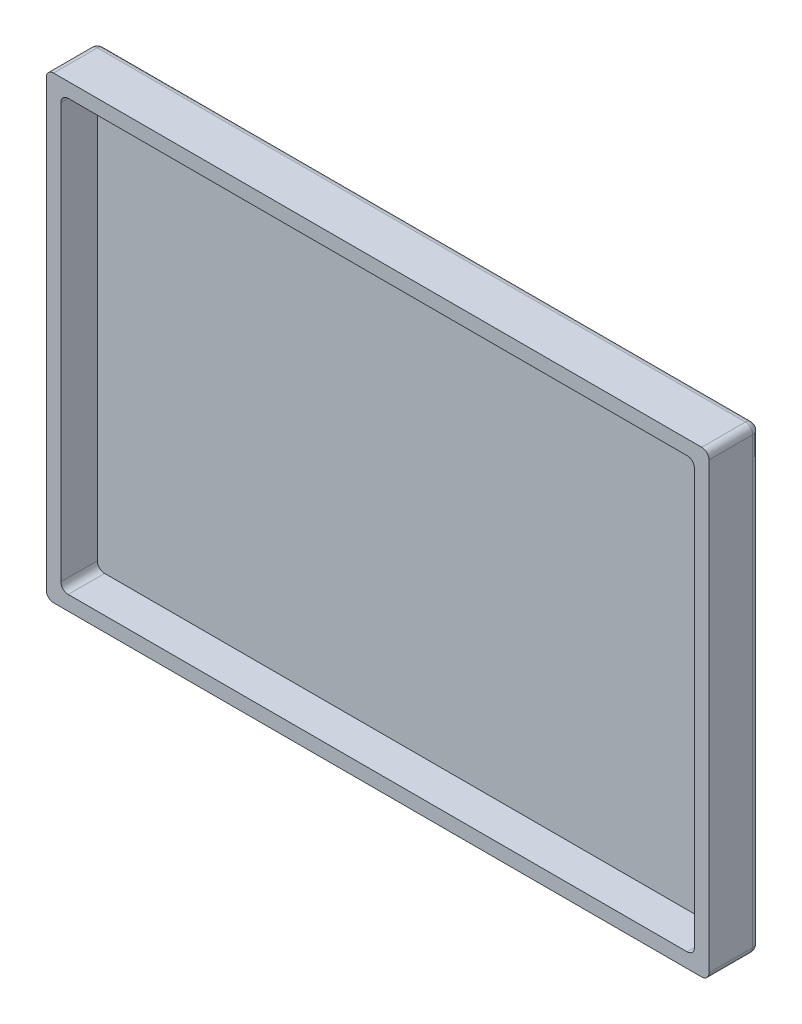
from build123d import *

# Parameters (mm, degrees)
ESBO_O1_W                = 91
ESBO_O1_H                = 63
ESBO_O1_W_2              = 87
ESBO_O1_H_2              = 59
RESSALTO_EXTRUS_O1_DEPTH = 5
ESBO_O2_W                = 91
ESBO_O2_H                = 63
RESSALTO_EXTRUS_O2_DEPTH = 2
FILETE6_R                = 1
FILETE7_R                = 1
FILETE10_R               = 1
FILETE11_R               = 1
FILETE12_R               = 1


with BuildPart() as part:
    # Esboço1 → Ressalto-extrusão1 (new body)
    with BuildSketch(Plane.XY):
        with Locations((-1.263340114, -15.201421801)):
            Rectangle(ESBO_O1_W, ESBO_O1_H)
        with Locations((-1.263340114, -15.201421801)):
            Rectangle(ESBO_O1_W_2, ESBO_O1_H_2, mode=Mode.SUBTRACT)
    extrude(amount=RESSALTO_EXTRUS_O1_DEPTH)

    # Esboço2 → Ressalto-extrusão2 (add)
    with BuildSketch(Plane(origin=(0, 0, 0), x_dir=(-1, 0, 0), z_dir=(0, 0, -1))):
        with Locations((1.263340114, -15.201421801)):
            Rectangle(ESBO_O2_W, ESBO_O2_H)
    extrude(amount=RESSALTO_EXTRUS_O2_DEPTH)

    # Filete6
    filete6_edges = [part.edges().sort_by_distance(p)[0] for p in [
        (42.236659886, 14.298578199, 2.5),
    ]]
    fillet(filete6_edges, radius=FILETE6_R)

    # Filete7
    filete7_edges = [part.edges().sort_by_distance(p)[0] for p in [
        (-44.763340114, 14.298578199, 2.5),
        (-44.763340114, -44.701421801, 2.5),
        (42.236659886, -44.701421801, 2.5),
    ]]
    fillet(filete7_edges, radius=FILETE7_R)

    # Filete10
    filete10_edges = [part.edges().sort_by_distance(p)[0] for p in [
        (-46.763340114, -46.701421801, 1.5),
    ]]
    fillet(filete10_edges, radius=FILETE10_R)

    # Filete11
    filete11_edges = [part.edges().sort_by_distance(p)[0] for p in [
        (-46.763340114, 16.298578199, 1.5),
        (44.236659886, 16.298578199, 1.5),
        (44.236659886, -46.701421801, 1.5),
    ]]
    fillet(filete11_edges, radius=FILETE11_R)

    # Filete12
    filete12_edges = [part.edges().sort_by_distance(p)[0] for p in [
        (-46.763340114, -15.201421801, -2),
        (-46.470446895, -46.408528582, -2),
        (44.236659886, -15.201421801, -2),
        (-1.263340114, -46.701421801, -2),
        (-1.263340114, 16.298578199, -2),
        (-46.470446895, 16.00568498, -2),
        (43.943766667, 16.00568498, -2),
        (43.943766667, -46.408528582, -2),
    ]]
    fillet(filete12_edges, radius=FILETE12_R)


solid = part.part
